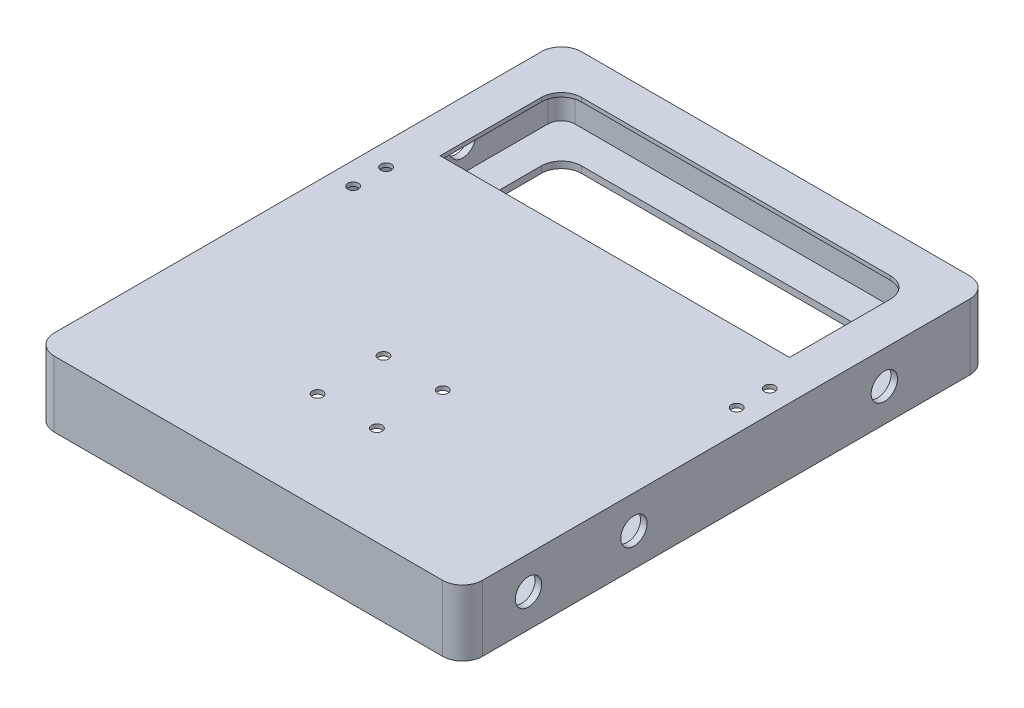
from build123d import *

# Parameters (mm, degrees)
BOSS_EXTRUDE1_DEPTH     = 50
SHELL1_T                = -5
SKETCH2_R               = 10
CUT_EXTRUDE1_DEPTH      = 325
BOSS_EXTRUDE2_DEPTH     = 3
CUT_EXTRUDE2_DEPTH      = 50
SKETCH6_R               = 4
CUT_EXTRUDE3_DEPTH      = 46
CUT_EXTRUDE3_DEPTH_BACK = 6
SKETCH7_W               = 265
SKETCH7_H               = 3
BOSS_EXTRUDE4_DEPTH     = 187
SKETCH8_R               = 4
CUT_EXTRUDE4_DEPTH      = 3
SKETCH7_2_W             = 265
SKETCH7_2_H             = 3
BOSS_EXTRUDE5_DEPTH     = 78


with BuildPart() as part:
    # Sketch1 → Boss-Extrude1 (new body)
    with BuildSketch(Plane(origin=(0, 0, 0), x_dir=(1, 0, 0), z_dir=(0, 1, 0))):
        with BuildLine():
            Line((-147.30160795, -200), (147.30160795, -200))
            ThreePointArc((147.30160795, -200), (158.048494032, -195.548494032), (162.5, -184.80160795))
            Line((162.5, -184.80160795), (162.5, 184.80160795))
            ThreePointArc((162.5, 184.80160795), (158.048494032, 195.548494032), (147.30160795, 200))
            Line((147.30160795, 200), (-147.30160795, 200))
            ThreePointArc((-147.30160795, 200), (-158.048494032, 195.548494032), (-162.5, 184.80160795))
            Line((-162.5, 184.80160795), (-162.5, -184.80160795))
            ThreePointArc((-162.5, -184.80160795), (-158.048494032, -195.548494032), (-147.30160795, -200))
        make_face()
    extrude(amount=BOSS_EXTRUDE1_DEPTH)

    # Shell1
    shell1_openings = [part.faces().sort_by_distance(p)[0] for p in [
        (0, 50, 0),
    ]]
    offset(amount=SHELL1_T, openings=shell1_openings, kind=Kind.INTERSECTION)

    # Sketch2 → Cut-Extrude1 (cut)
    with BuildSketch(Plane(origin=(162.5, 0, 0), x_dir=(0, 0, -1), z_dir=(1, 0, 0))):
        with Locations((-150, 25)):
            Circle(SKETCH2_R)
        with Locations((120, 25)):
            Circle(SKETCH2_R)
        with Locations((-70, 25)):
            Circle(SKETCH2_R)
    extrude(amount=-CUT_EXTRUDE1_DEPTH, mode=Mode.SUBTRACT)

    # Sketch3 → Boss-Extrude2 (add)
    with BuildSketch(Plane(origin=(0, 50, 0), x_dir=(1, 0, 0), z_dir=(0, 1, 0))):
        with BuildLine():
            Line((147.30160795, 195), (-147.30160795, 195))
            ThreePointArc((-147.30160795, 195), (-154.512960126, 192.012960126), (-157.5, 184.80160795))
            Line((-157.5, 184.80160795), (-157.5, -184.80160795))
            ThreePointArc((-157.5, -184.80160795), (-154.512960126, -192.012960126), (-147.30160795, -195))
            Line((-147.30160795, -195), (147.30160795, -195))
            ThreePointArc((147.30160795, -195), (154.512960126, -192.012960126), (157.5, -184.80160795))
            Line((157.5, -184.80160795), (157.5, 184.80160795))
            ThreePointArc((157.5, 184.80160795), (154.512960126, 192.012960126), (147.30160795, 195))
        make_face()
    extrude(amount=-BOSS_EXTRUDE2_DEPTH)

    # Sketch4 → Cut-Extrude2 (cut)
    with BuildSketch(Plane(origin=(0, 50, 0), x_dir=(1, 0, 0), z_dir=(0, 1, 0))):
        with BuildLine():
            Line((-117.30160795, -170), (117.30160795, -170))
            ThreePointArc((117.30160795, -170), (128.048494032, -165.548494032), (132.5, -154.80160795))
            Line((132.5, -154.80160795), (132.5, 154.80160795))
            ThreePointArc((132.5, 154.80160795), (128.048494032, 165.548494032), (117.30160795, 170))
            Line((117.30160795, 170), (-117.30160795, 170))
            ThreePointArc((-117.30160795, 170), (-128.048494032, 165.548494032), (-132.5, 154.80160795))
            Line((-132.5, 154.80160795), (-132.5, -154.80160795))
            ThreePointArc((-132.5, -154.80160795), (-128.048494032, -165.548494032), (-117.30160795, -170))
        make_face()
    extrude(amount=-CUT_EXTRUDE2_DEPTH, mode=Mode.SUBTRACT)

    # Sketch6 → Cut-Extrude3 (cut, two sides)
    with BuildSketch(Plane(origin=(0, 5, 0), x_dir=(1, 0, 0), z_dir=(0, 1, 0))) as cut_extrude3_sk:
        with Locations((-145.5, 50)):
            Circle(SKETCH6_R)
        with Locations((-145.5, 25)):
            Circle(SKETCH6_R)
        with Locations((145.5, 25)):
            Circle(SKETCH6_R)
        with Locations((145.5, 50)):
            Circle(SKETCH6_R)
    extrude(amount=CUT_EXTRUDE3_DEPTH, mode=Mode.SUBTRACT)
    extrude(cut_extrude3_sk.sketch, amount=-CUT_EXTRUDE3_DEPTH_BACK, mode=Mode.SUBTRACT)

    # Sketch7 → Boss-Extrude4 (add)
    with BuildSketch(Plane.XY):
        with Locations((0, 48.5)):
            Rectangle(SKETCH7_W, SKETCH7_H)
    extrude(amount=BOSS_EXTRUDE4_DEPTH)

    # Sketch8 → Cut-Extrude4 (cut)
    with BuildSketch(Plane(origin=(0, 50, 0), x_dir=(1, 0, 0), z_dir=(0, 1, 0))):
        with Locations((-22.5, -125)):
            Circle(SKETCH8_R)
        with Locations((-22.5, -75)):
            Circle(SKETCH8_R)
        with Locations((22.5, -125)):
            Circle(SKETCH8_R)
        with Locations((22.5, -75)):
            Circle(SKETCH8_R)
    extrude(amount=-CUT_EXTRUDE4_DEPTH, mode=Mode.SUBTRACT)

    # Sketch7_2 → Boss-Extrude5 (add)
    with BuildSketch(Plane.XY):
        with Locations((0, 48.5)):
            Rectangle(SKETCH7_2_W, SKETCH7_2_H)
    extrude(amount=-BOSS_EXTRUDE5_DEPTH)


solid = part.part
